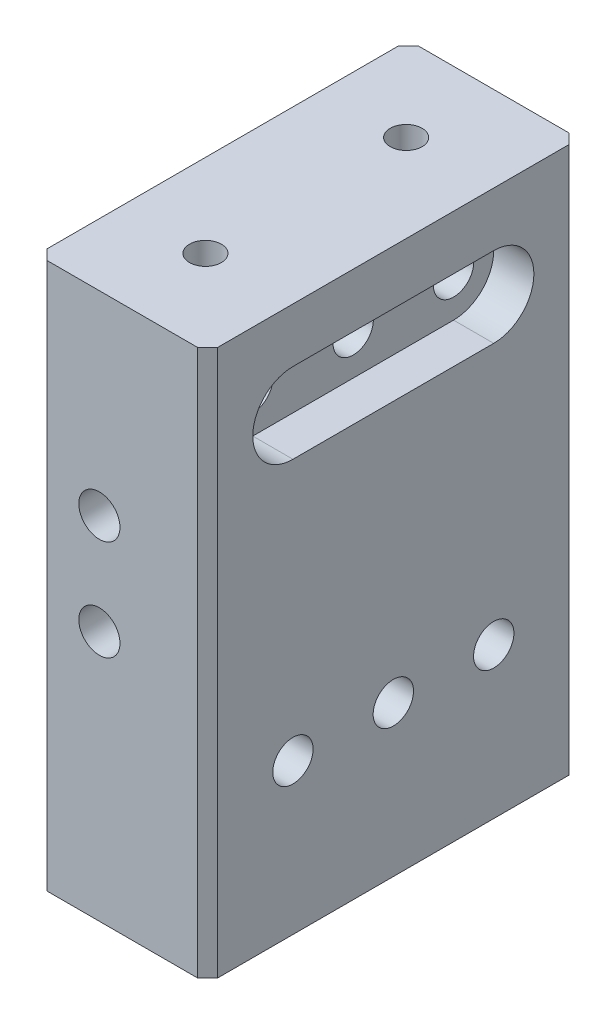
from build123d import *

# Parameters (mm, degrees)
SKETCH1_W           = 21.59
SKETCH1_H           = 46.99
BOSS_EXTRUDE1_DEPTH = 31.75
SKETCH2_R           = 2.6035
CUT_EXTRUDE1_DEPTH  = 47.99
SKETCH4_R           = 2.5527
CUT_EXTRUDE3_DEPTH  = 22.59
CUT_EXTRUDE5_DEPTH  = 5.08
SKETCH8_W           = 21.59
SKETCH8_H           = 46.99
BOSS_EXTRUDE2_DEPTH = 5.588
SKETCH9_R           = 2.0193
CUT_EXTRUDE6_DEPTH  = 5.08
SKETCH10_R          = 2.5527
CUT_EXTRUDE7_DEPTH  = 22.59
CHAMFER1_SIZE       = 1.27


with BuildPart() as part:
    # Sketch1 → Boss-Extrude1 (new body, symmetric)
    with BuildSketch(Plane(origin=(0, 0, 0), x_dir=(1, 0, 0), z_dir=(0, 1, 0))):
        Rectangle(SKETCH1_W, SKETCH1_H)
    extrude(amount=BOSS_EXTRUDE1_DEPTH, both=True)

    # Sketch2 → Cut-Extrude1 (cut, through all)
    with BuildSketch(Plane.XY.offset(23.495)):
        with Locations((-2.8956, 12.7)):
            Circle(SKETCH2_R)
        with Locations((-2.8956, 0)):
            Circle(SKETCH2_R)
    extrude(amount=-CUT_EXTRUDE1_DEPTH, mode=Mode.SUBTRACT)

    # Sketch4 → Cut-Extrude3 (cut, through all)
    with BuildSketch(Plane(origin=(10.795, 0, 0), x_dir=(0, 0, -1), z_dir=(1, 0, 0))):
        with Locations((-12.7, 25.4)):
            Circle(SKETCH4_R)
        with Locations((12.7, 25.4)):
            Circle(SKETCH4_R)
        with Locations((0, 25.4)):
            Circle(SKETCH4_R)
    extrude(amount=-CUT_EXTRUDE3_DEPTH, mode=Mode.SUBTRACT)

    # Sketch7 → Cut-Extrude5 (cut)
    with BuildSketch(Plane(origin=(10.795, 0, 0), x_dir=(0, 0, -1), z_dir=(1, 0, 0))):
        with BuildLine():
            Line((-12.7, 30.48), (12.7, 30.48))
            ThreePointArc((12.7, 30.48), (17.78, 25.4), (12.7, 20.32))
            Line((12.7, 20.32), (-12.7, 20.32))
            ThreePointArc((-12.7, 20.32), (-17.78, 25.4), (-12.7, 30.48))
        make_face()
    extrude(amount=-CUT_EXTRUDE5_DEPTH, mode=Mode.SUBTRACT)

    # Sketch8 → Boss-Extrude2 (add)
    with BuildSketch(Plane(origin=(0, 31.75, 0), x_dir=(1, 0, 0), z_dir=(0, 1, 0))):
        Rectangle(SKETCH8_W, SKETCH8_H)
    extrude(amount=BOSS_EXTRUDE2_DEPTH)

    # Sketch9 → Cut-Extrude6 (cut)
    with BuildSketch(Plane(origin=(0, 37.338, 0), x_dir=(1, 0, 0), z_dir=(0, 1, 0))):
        with Locations((-0.2794, 12.696926228)):
            Circle(SKETCH9_R)
        with Locations((-0.2794, -12.696926228)):
            Circle(SKETCH9_R)
    extrude(amount=-CUT_EXTRUDE6_DEPTH, mode=Mode.SUBTRACT)

    # Sketch10 → Cut-Extrude7 (cut, through all)
    with BuildSketch(Plane(origin=(10.795, 0, 0), x_dir=(0, 0, -1), z_dir=(1, 0, 0))):
        with Locations((0, -12.7)):
            Circle(SKETCH10_R)
        with Locations((12.7, -12.7)):
            Circle(SKETCH10_R)
        with Locations((-12.7, -12.7)):
            Circle(SKETCH10_R)
    extrude(amount=-CUT_EXTRUDE7_DEPTH, mode=Mode.SUBTRACT)

    # Chamfer1
    chamfer1_edges = [part.edges().sort_by_distance(p)[0] for p in [
        (10.795, 2.794, 23.495),
        (-10.795, 2.794, 23.495),
        (-10.795, 2.794, -23.495),
        (10.795, 2.794, -23.495),
    ]]
    chamfer(chamfer1_edges, length=CHAMFER1_SIZE)


solid = part.part
